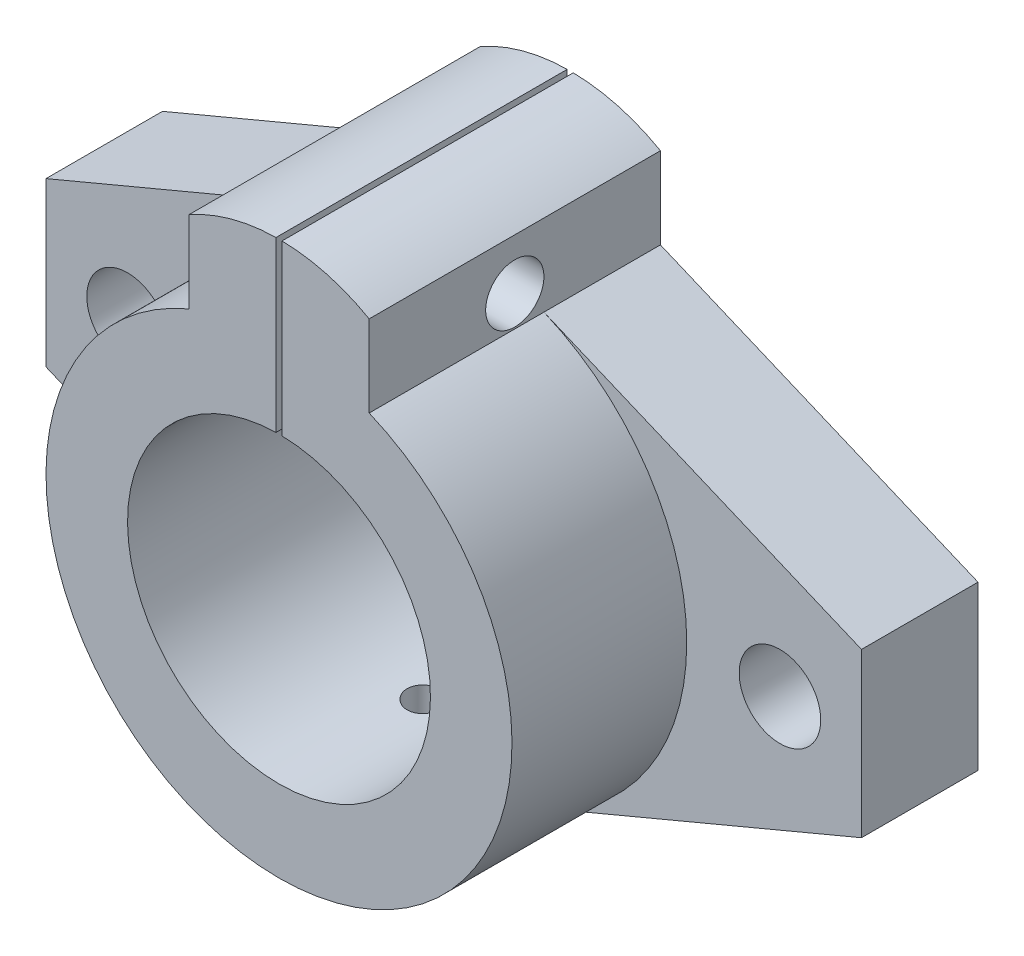
from build123d import *

# Parameters (mm, degrees)
SKETCH_1_R          = 3.5
SKETCH_1_R_2        = 13
EXTRUDE_2_DEPTH     = 10
SKETCH_2_R          = 13
EXTRUDE_3_DEPTH     = 15
SKETCH_3_W          = 0.517195108
SKETCH_3_H          = 18.726193104
CUT_EXTRUDE_1_DEPTH = 26
SKETCH_4_R          = 2.5
CUT_EXTRUDE_2_DEPTH = 43.740275714
SKETCH_5_R          = 1.5
CUT_EXTRUDE_3_DEPTH = 21


with BuildPart() as part:
    # 草图1 → 凸台-拉伸2 (new body)
    with BuildSketch(Plane.XY):
        with BuildLine():
            Line((-35, -7), (-7.740275714, -18.44147857))
            ThreePointArc((-7.740275714, -18.44147857), (0, -20), (7.740275714, -18.44147857))
            Line((7.740275714, -18.44147857), (35, -7))
            Line((35, -7), (35, 7))
            Line((35, 7), (7.740275714, 18.44147857))
            Line((7.740275714, 18.44147857), (7.740275714, 25.44147857))
            ThreePointArc((7.740275714, 25.44147857), (0, 27.494244152), (-7.740275714, 25.44147857))
            Line((-7.740275714, 25.44147857), (-7.740275714, 18.44147857))
            Line((-7.740275714, 18.44147857), (-35, 7))
            Line((-35, 7), (-35, -7))
        make_face()
        with Locations((-28, 0)):
            Circle(SKETCH_1_R, mode=Mode.SUBTRACT)
        Circle(SKETCH_1_R_2, mode=Mode.SUBTRACT)
        with Locations((28, 0)):
            Circle(SKETCH_1_R, mode=Mode.SUBTRACT)
    extrude(amount=EXTRUDE_2_DEPTH)

    # 草图2 → 凸台-拉伸3 (add)
    with BuildSketch(Plane.XY.offset(10)):
        with BuildLine():
            Line((-7.740275714, 18.44147857), (-7.740275714, 25.44147857))
            ThreePointArc((-7.740275714, 25.44147857), (0, 27.494244152), (7.740275714, 25.44147857))
            Line((7.740275714, 25.44147857), (7.740275714, 18.44147857))
            ThreePointArc((7.740275714, 18.44147857), (0, -20), (-7.740275714, 18.44147857))
        make_face()
        Circle(SKETCH_2_R, mode=Mode.SUBTRACT)
    extrude(amount=EXTRUDE_3_DEPTH)

    # 草图3 → 切除-拉伸1 (cut, through all)
    with BuildSketch(Plane.XY.offset(25)):
        with Locations((0, 21.741202931)):
            Rectangle(SKETCH_3_W, SKETCH_3_H)
    extrude(amount=-CUT_EXTRUDE_1_DEPTH, mode=Mode.SUBTRACT)

    # 草图4 → 切除-拉伸2 (cut, through all)
    with BuildSketch(Plane(origin=(7.740275714, 0, 0), x_dir=(0, 0, -1), z_dir=(1, 0, 0))):
        with Locations((-12.5, 21.086423576)):
            Circle(SKETCH_4_R)
    extrude(amount=-CUT_EXTRUDE_2_DEPTH, mode=Mode.SUBTRACT)

    # 草图5 → 切除-拉伸3 (cut, through all)
    with BuildSketch(Plane(origin=(0, 0, 0), x_dir=(1, 0, 0), z_dir=(0, 1, 0))):
        with Locations((0, -12.5)):
            Circle(SKETCH_5_R)
    extrude(amount=-CUT_EXTRUDE_3_DEPTH, mode=Mode.SUBTRACT)


solid = part.part
